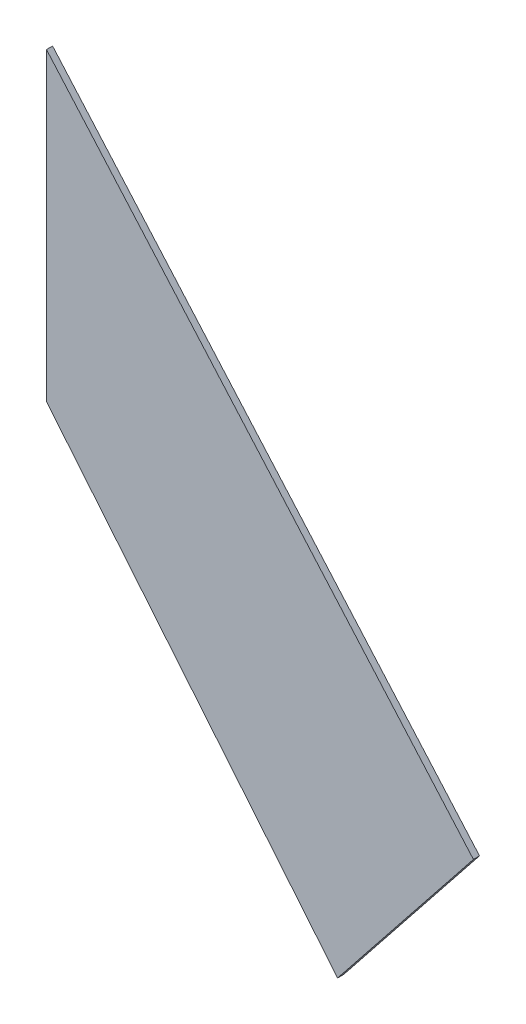
from build123d import *

# Parameters (mm, degrees)
SALIENTE_EXTRUIR1_DEPTH = 0.1


with BuildPart() as part:
    # Model → Saliente-Extruir1 (new body)
    with BuildSketch(Plane.XY):
        Polygon((42.615733425, 18.867885317), (35.615733425, 26.867885317), (35.615733425, 21.867885317), (40.388764026, 16.070451786), align=None)
    extrude(amount=SALIENTE_EXTRUIR1_DEPTH)


solid = part.part
